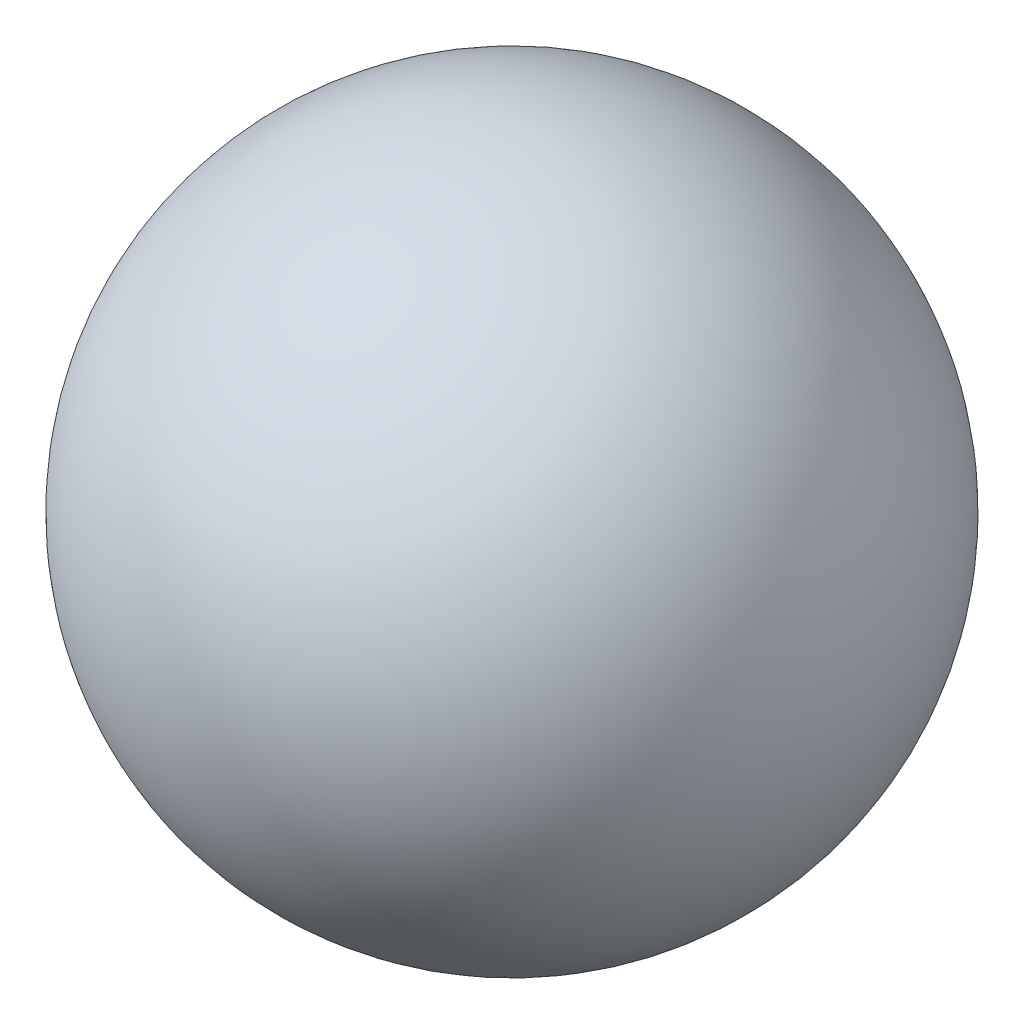
from build123d import *


with BuildPart() as part:
    # Sketch2 → Revolve1 (revolve)
    with BuildSketch(Plane(origin=(0, 0, 0), x_dir=(1, 0, 0), z_dir=(0, 1, 0))):
        with BuildLine():
            Line((0, 25.4), (0, -25.4))
            ThreePointArc((0, -25.4), (25.4, 0), (0, 25.4))
        make_face()
    revolve(axis=Axis((0, 0, -25.4), (0, 0, 1)))


solid = part.part
